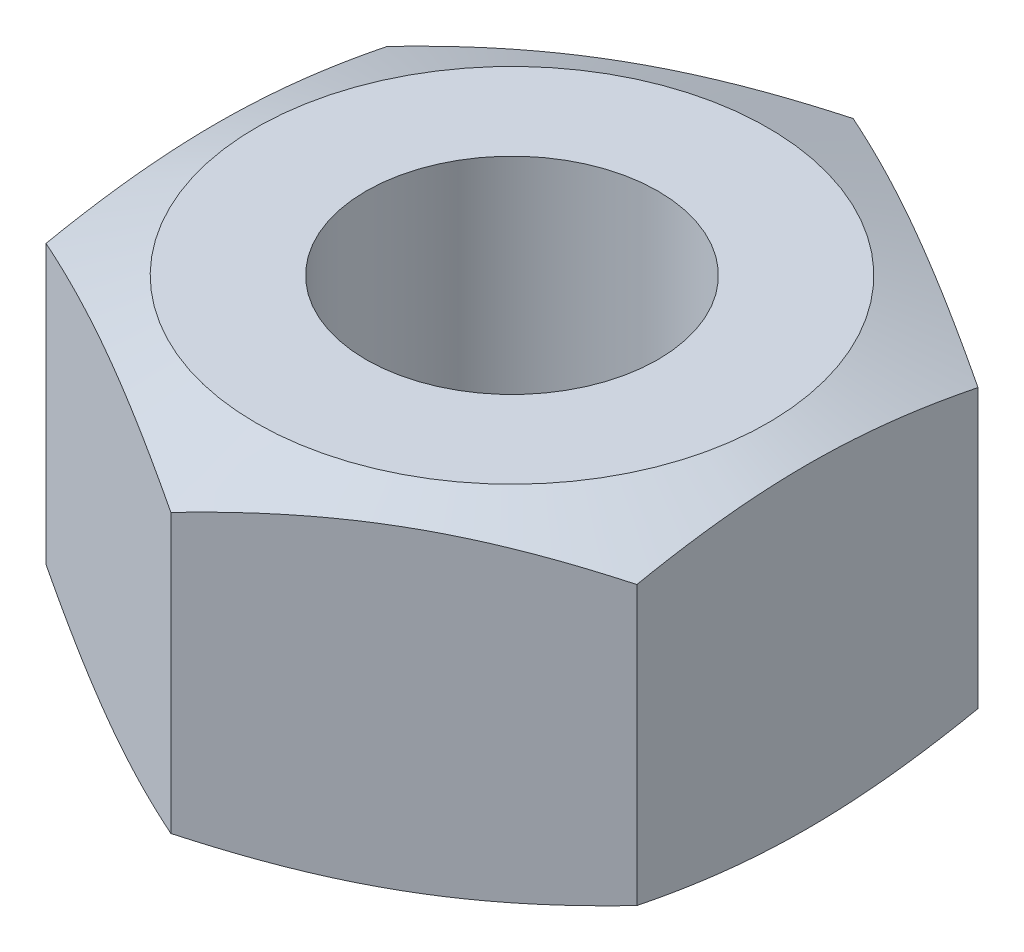
from build123d import *

# Parameters (mm, degrees)
SKETCH1_R           = 4.2
BOSS_EXTRUDE1_DEPTH = 10


with BuildPart() as part:
    # Sketch1 → Boss-Extrude1 (new body)
    with BuildSketch(Plane(origin=(0, 0, 0), x_dir=(1, 0, 0), z_dir=(0, 1, 0))):
        Polygon((0, 9.814954576), (-8.5, 4.907477288), (-8.5, -4.907477288), (0, -9.814954576), (8.5, -4.907477288), (8.5, 4.907477288), align=None)
        Circle(SKETCH1_R, mode=Mode.SUBTRACT)
    extrude(amount=BOSS_EXTRUDE1_DEPTH)

    # Sketch2 → Cut-Revolve1 (revolve, cut)
    with BuildSketch(Plane(origin=(0, 0, 0), x_dir=(0, 0, -1), z_dir=(1, 0, 0))):
        Polygon((-9.814954576, 9), (-7.361215932, 10), (-9.814954576, 10), align=None)
        Polygon((-7.361215932, 0), (-9.814954576, 0), (-9.814954576, 1), align=None)
    revolve(axis=Axis((0, 13.206770677, 0), (0, -1, 0)), mode=Mode.SUBTRACT)


solid = part.part
